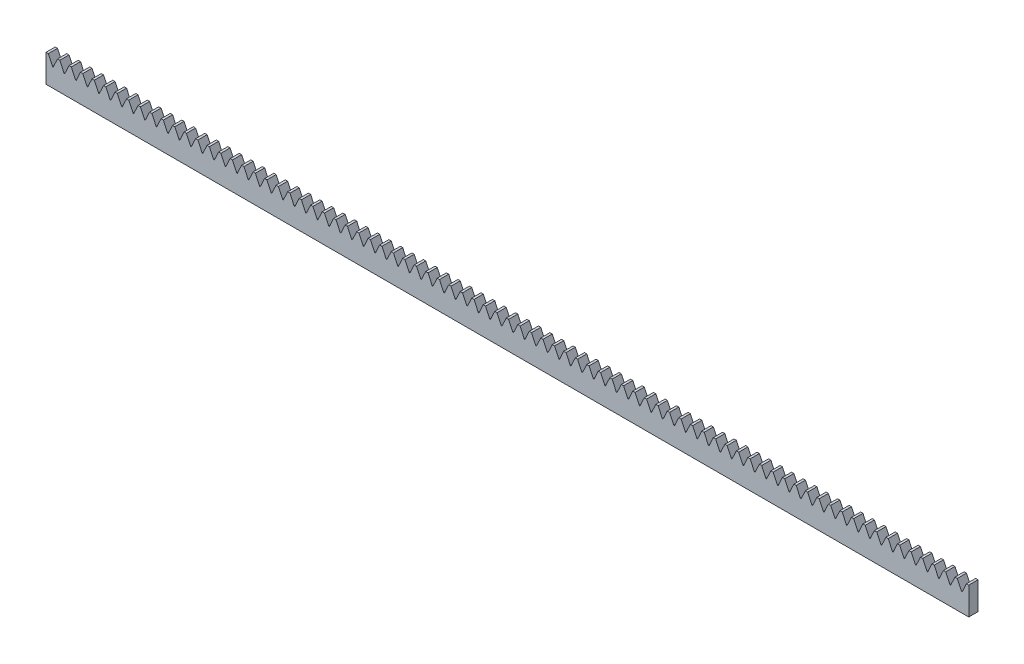
from build123d import *

# Parameters (mm, degrees)
BOSS_EXTRUDE1_DEPTH = 10


with BuildPart() as part:
    # Sketch2 → Boss-Extrude1 (new body)
    with BuildSketch(Plane.XY):
        with BuildLine():
            Line((0, 0), (0, 30))
            Line((0, 30), (2.5, 30))
            Line((2.5, 30), (7.028457818, 20.288690869))
            ThreePointArc((7.028457818, 20.288690869), (7.481611712, 20), (7.934765605, 20.288690869))
            Line((7.934765605, 20.288690869), (12.463223424, 30))
            Line((12.463223424, 30), (14.963223424, 30))
            Line((14.963223424, 30), (19.491681242, 20.288690869))
            ThreePointArc((19.491681242, 20.288690869), (19.944835136, 20), (20.397989029, 20.288690869))
            Line((20.397989029, 20.288690869), (24.926446848, 30))
            Line((24.926446848, 30), (27.426446848, 30))
            Line((27.426446848, 30), (31.954904666, 20.288690869))
            ThreePointArc((31.954904666, 20.288690869), (32.40805856, 20), (32.861212453, 20.288690869))
            Line((32.861212453, 20.288690869), (37.389670272, 30))
            Line((37.389670272, 30), (39.889670272, 30))
            Line((39.889670272, 30), (44.41812809, 20.288690869))
            ThreePointArc((44.41812809, 20.288690869), (44.871281984, 20), (45.324435877, 20.288690869))
            Line((45.324435877, 20.288690869), (49.852893696, 30))
            Line((49.852893696, 30), (52.352893696, 30))
            Line((52.352893696, 30), (56.881351514, 20.288690869))
            ThreePointArc((56.881351514, 20.288690869), (57.334505408, 20), (57.787659301, 20.288690869))
            Line((57.787659301, 20.288690869), (62.31611712, 30))
            Line((62.31611712, 30), (64.81611712, 30))
            Line((64.81611712, 30), (69.344574938, 20.288690869))
            ThreePointArc((69.344574938, 20.288690869), (69.797728831, 20), (70.250882725, 20.288690869))
            Line((70.250882725, 20.288690869), (74.779340543, 30))
            Line((74.779340543, 30), (77.279340543, 30))
            Line((77.279340543, 30), (81.807798362, 20.288690869))
            ThreePointArc((81.807798362, 20.288690869), (82.260952255, 20), (82.714106149, 20.288690869))
            Line((82.714106149, 20.288690869), (87.242563967, 30))
            Line((87.242563967, 30), (89.742563967, 30))
            Line((89.742563967, 30), (94.271021786, 20.288690869))
            ThreePointArc((94.271021786, 20.288690869), (94.724175679, 20), (95.177329573, 20.288690869))
            Line((95.177329573, 20.288690869), (99.705787391, 30))
            Line((99.705787391, 30), (102.205787391, 30))
            Line((102.205787391, 30), (106.73424521, 20.288690869))
            ThreePointArc((106.73424521, 20.288690869), (107.187399103, 20), (107.640552997, 20.288690869))
            Line((107.640552997, 20.288690869), (112.169010815, 30))
            Line((112.169010815, 30), (114.669010815, 30))
            Line((114.669010815, 30), (119.197468634, 20.288690869))
            ThreePointArc((119.197468634, 20.288690869), (119.650622527, 20), (120.103776421, 20.288690869))
            Line((120.103776421, 20.288690869), (124.632234239, 30))
            Line((124.632234239, 30), (127.132234239, 30))
            Line((127.132234239, 30), (131.660692058, 20.288690869))
            ThreePointArc((131.660692058, 20.288690869), (132.113845951, 20), (132.566999845, 20.288690869))
            Line((132.566999845, 20.288690869), (137.095457663, 30))
            Line((137.095457663, 30), (139.595457663, 30))
            Line((139.595457663, 30), (144.123915481, 20.288690869))
            ThreePointArc((144.123915481, 20.288690869), (144.577069375, 20), (145.030223268, 20.288690869))
            Line((145.030223268, 20.288690869), (149.558681087, 30))
            Line((149.558681087, 30), (152.058681087, 30))
            Line((152.058681087, 30), (156.587138905, 20.288690869))
            ThreePointArc((156.587138905, 20.288690869), (157.040292799, 20), (157.493446692, 20.288690869))
            Line((157.493446692, 20.288690869), (162.021904511, 30))
            Line((162.021904511, 30), (164.521904511, 30))
            Line((164.521904511, 30), (169.050362329, 20.288690869))
            ThreePointArc((169.050362329, 20.288690869), (169.503516223, 20), (169.956670116, 20.288690869))
            Line((169.956670116, 20.288690869), (174.485127935, 30))
            Line((174.485127935, 30), (176.985127935, 30))
            Line((176.985127935, 30), (181.513585753, 20.288690869))
            ThreePointArc((181.513585753, 20.288690869), (181.966739647, 20), (182.41989354, 20.288690869))
            Line((182.41989354, 20.288690869), (186.948351359, 30))
            Line((186.948351359, 30), (189.448351359, 30))
            Line((189.448351359, 30), (193.976809177, 20.288690869))
            ThreePointArc((193.976809177, 20.288690869), (194.429963071, 20), (194.883116964, 20.288690869))
            Line((194.883116964, 20.288690869), (199.411574783, 30))
            Line((199.411574783, 30), (201.911574783, 30))
            Line((201.911574783, 30), (206.440032601, 20.288690869))
            ThreePointArc((206.440032601, 20.288690869), (206.893186494, 20), (207.346340388, 20.288690869))
            Line((207.346340388, 20.288690869), (211.874798206, 30))
            Line((211.874798206, 30), (214.374798206, 30))
            Line((214.374798206, 30), (218.903256025, 20.288690869))
            ThreePointArc((218.903256025, 20.288690869), (219.356409918, 20), (219.809563812, 20.288690869))
            Line((219.809563812, 20.288690869), (224.33802163, 30))
            Line((224.33802163, 30), (226.83802163, 30))
            Line((226.83802163, 30), (231.366479449, 20.288690869))
            ThreePointArc((231.366479449, 20.288690869), (231.819633342, 20), (232.272787236, 20.288690869))
            Line((232.272787236, 20.288690869), (236.801245054, 30))
            Line((236.801245054, 30), (239.301245054, 30))
            Line((239.301245054, 30), (243.829702873, 20.288690869))
            ThreePointArc((243.829702873, 20.288690869), (244.282856766, 20), (244.73601066, 20.288690869))
            Line((244.73601066, 20.288690869), (249.264468478, 30))
            Line((249.264468478, 30), (251.764468478, 30))
            Line((251.764468478, 30), (256.292926297, 20.288690869))
            ThreePointArc((256.292926297, 20.288690869), (256.74608019, 20), (257.199234084, 20.288690869))
            Line((257.199234084, 20.288690869), (261.727691902, 30))
            Line((261.727691902, 30), (264.227691902, 30))
            Line((264.227691902, 30), (268.75614972, 20.288690869))
            ThreePointArc((268.75614972, 20.288690869), (269.209303614, 20), (269.662457508, 20.288690869))
            Line((269.662457508, 20.288690869), (274.190915326, 30))
            Line((274.190915326, 30), (276.690915326, 30))
            Line((276.690915326, 30), (281.219373144, 20.288690869))
            ThreePointArc((281.219373144, 20.288690869), (281.672527038, 20), (282.125680931, 20.288690869))
            Line((282.125680931, 20.288690869), (286.65413875, 30))
            Line((286.65413875, 30), (289.15413875, 30))
            Line((289.15413875, 30), (293.682596568, 20.288690869))
            ThreePointArc((293.682596568, 20.288690869), (294.135750462, 20), (294.588904355, 20.288690869))
            Line((294.588904355, 20.288690869), (299.117362174, 30))
            Line((299.117362174, 30), (301.617362174, 30))
            Line((301.617362174, 30), (306.145819992, 20.288690869))
            ThreePointArc((306.145819992, 20.288690869), (306.598973886, 20), (307.052127779, 20.288690869))
            Line((307.052127779, 20.288690869), (311.580585598, 30))
            Line((311.580585598, 30), (314.080585598, 30))
            Line((314.080585598, 30), (318.609043416, 20.288690869))
            ThreePointArc((318.609043416, 20.288690869), (319.06219731, 20), (319.515351203, 20.288690869))
            Line((319.515351203, 20.288690869), (324.043809022, 30))
            Line((324.043809022, 30), (326.543809022, 30))
            Line((326.543809022, 30), (331.07226684, 20.288690869))
            ThreePointArc((331.07226684, 20.288690869), (331.525420734, 20), (331.978574627, 20.288690869))
            Line((331.978574627, 20.288690869), (336.507032446, 30))
            Line((336.507032446, 30), (339.007032446, 30))
            Line((339.007032446, 30), (343.535490264, 20.288690869))
            ThreePointArc((343.535490264, 20.288690869), (343.988644157, 20), (344.441798051, 20.288690869))
            Line((344.441798051, 20.288690869), (348.970255869, 30))
            Line((348.970255869, 30), (351.470255869, 30))
            Line((351.470255869, 30), (355.998713688, 20.288690869))
            ThreePointArc((355.998713688, 20.288690869), (356.451867581, 20), (356.905021475, 20.288690869))
            Line((356.905021475, 20.288690869), (361.433479293, 30))
            Line((361.433479293, 30), (363.933479293, 30))
            Line((363.933479293, 30), (368.461937112, 20.288690869))
            ThreePointArc((368.461937112, 20.288690869), (368.915091005, 20), (369.368244899, 20.288690869))
            Line((369.368244899, 20.288690869), (373.896702717, 30))
            Line((373.896702717, 30), (376.396702717, 30))
            Line((376.396702717, 30), (380.925160536, 20.288690869))
            ThreePointArc((380.925160536, 20.288690869), (381.378314429, 20), (381.831468323, 20.288690869))
            Line((381.831468323, 20.288690869), (386.359926141, 30))
            Line((386.359926141, 30), (388.859926141, 30))
            Line((388.859926141, 30), (393.38838396, 20.288690869))
            ThreePointArc((393.38838396, 20.288690869), (393.841537853, 20), (394.294691747, 20.288690869))
            Line((394.294691747, 20.288690869), (398.823149565, 30))
            Line((398.823149565, 30), (401.323149565, 30))
            Line((401.323149565, 30), (405.851607383, 20.288690869))
            ThreePointArc((405.851607383, 20.288690869), (406.304761277, 20), (406.757915171, 20.288690869))
            Line((406.757915171, 20.288690869), (411.286372989, 30))
            Line((411.286372989, 30), (413.786372989, 30))
            Line((413.786372989, 30), (418.314830807, 20.288690869))
            ThreePointArc((418.314830807, 20.288690869), (418.767984701, 20), (419.221138594, 20.288690869))
            Line((419.221138594, 20.288690869), (423.749596413, 30))
            Line((423.749596413, 30), (426.249596413, 30))
            Line((426.249596413, 30), (430.778054231, 20.288690869))
            ThreePointArc((430.778054231, 20.288690869), (431.231208125, 20), (431.684362018, 20.288690869))
            Line((431.684362018, 20.288690869), (436.212819837, 30))
            Line((436.212819837, 30), (438.712819837, 30))
            Line((438.712819837, 30), (443.241277655, 20.288690869))
            ThreePointArc((443.241277655, 20.288690869), (443.694431549, 20), (444.147585442, 20.288690869))
            Line((444.147585442, 20.288690869), (448.676043261, 30))
            Line((448.676043261, 30), (451.176043261, 30))
            Line((451.176043261, 30), (455.704501079, 20.288690869))
            ThreePointArc((455.704501079, 20.288690869), (456.157654973, 20), (456.610808866, 20.288690869))
            Line((456.610808866, 20.288690869), (461.139266685, 30))
            Line((461.139266685, 30), (463.639266685, 30))
            Line((463.639266685, 30), (468.167724503, 20.288690869))
            ThreePointArc((468.167724503, 20.288690869), (468.620878397, 20), (469.07403229, 20.288690869))
            Line((469.07403229, 20.288690869), (473.602490108, 30))
            Line((473.602490108, 30), (476.102490108, 30))
            Line((476.102490108, 30), (480.630947927, 20.288690869))
            ThreePointArc((480.630947927, 20.288690869), (481.08410182, 20), (481.537255714, 20.288690869))
            Line((481.537255714, 20.288690869), (486.065713532, 30))
            Line((486.065713532, 30), (488.565713532, 30))
            Line((488.565713532, 30), (493.094171351, 20.288690869))
            ThreePointArc((493.094171351, 20.288690869), (493.547325244, 20), (494.000479138, 20.288690869))
            Line((494.000479138, 20.288690869), (498.528936956, 30))
            Line((498.528936956, 30), (501.028936956, 30))
            Line((501.028936956, 30), (505.557394775, 20.288690869))
            ThreePointArc((505.557394775, 20.288690869), (506.010548668, 20), (506.463702562, 20.288690869))
            Line((506.463702562, 20.288690869), (510.99216038, 30))
            Line((510.99216038, 30), (513.49216038, 30))
            Line((513.49216038, 30), (518.020618199, 20.288690869))
            ThreePointArc((518.020618199, 20.288690869), (518.473772092, 20), (518.926925986, 20.288690869))
            Line((518.926925986, 20.288690869), (523.455383804, 30))
            Line((523.455383804, 30), (525.955383804, 30))
            Line((525.955383804, 30), (530.483841623, 20.288690869))
            ThreePointArc((530.483841623, 20.288690869), (530.936995516, 20), (531.39014941, 20.288690869))
            Line((531.39014941, 20.288690869), (535.918607228, 30))
            Line((535.918607228, 30), (538.418607228, 30))
            Line((538.418607228, 30), (542.947065046, 20.288690869))
            ThreePointArc((542.947065046, 20.288690869), (543.40021894, 20), (543.853372833, 20.288690869))
            Line((543.853372833, 20.288690869), (548.381830652, 30))
            Line((548.381830652, 30), (550.881830652, 30))
            Line((550.881830652, 30), (555.41028847, 20.288690869))
            ThreePointArc((555.41028847, 20.288690869), (555.863442364, 20), (556.316596257, 20.288690869))
            Line((556.316596257, 20.288690869), (560.845054076, 30))
            Line((560.845054076, 30), (563.345054076, 30))
            Line((563.345054076, 30), (567.873511894, 20.288690869))
            ThreePointArc((567.873511894, 20.288690869), (568.326665788, 20), (568.779819681, 20.288690869))
            Line((568.779819681, 20.288690869), (573.3082775, 30))
            Line((573.3082775, 30), (575.8082775, 30))
            Line((575.8082775, 30), (580.336735318, 20.288690869))
            ThreePointArc((580.336735318, 20.288690869), (580.789889212, 20), (581.243043105, 20.288690869))
            Line((581.243043105, 20.288690869), (585.771500924, 30))
            Line((585.771500924, 30), (588.271500924, 30))
            Line((588.271500924, 30), (592.799958742, 20.288690869))
            ThreePointArc((592.799958742, 20.288690869), (593.253112636, 20), (593.706266529, 20.288690869))
            Line((593.706266529, 20.288690869), (598.234724348, 30))
            Line((598.234724348, 30), (600.734724348, 30))
            Line((600.734724348, 30), (605.263182166, 20.288690869))
            ThreePointArc((605.263182166, 20.288690869), (605.71633606, 20), (606.169489953, 20.288690869))
            Line((606.169489953, 20.288690869), (610.697947771, 30))
            Line((610.697947771, 30), (613.197947771, 30))
            Line((613.197947771, 30), (617.72640559, 20.288690869))
            ThreePointArc((617.72640559, 20.288690869), (618.179559483, 20), (618.632713377, 20.288690869))
            Line((618.632713377, 20.288690869), (623.161171195, 30))
            Line((623.161171195, 30), (625.661171195, 30))
            Line((625.661171195, 30), (630.189629014, 20.288690869))
            ThreePointArc((630.189629014, 20.288690869), (630.642782907, 20), (631.095936801, 20.288690869))
            Line((631.095936801, 20.288690869), (635.624394619, 30))
            Line((635.624394619, 30), (638.124394619, 30))
            Line((638.124394619, 30), (642.652852438, 20.288690869))
            ThreePointArc((642.652852438, 20.288690869), (643.106006331, 20), (643.559160225, 20.288690869))
            Line((643.559160225, 20.288690869), (648.087618043, 30))
            Line((648.087618043, 30), (650.587618043, 30))
            Line((650.587618043, 30), (655.116075862, 20.288690869))
            ThreePointArc((655.116075862, 20.288690869), (655.569229755, 20), (656.022383649, 20.288690869))
            Line((656.022383649, 20.288690869), (660.550841467, 30))
            Line((660.550841467, 30), (663.050841467, 30))
            Line((663.050841467, 30), (667.579299286, 20.288690869))
            ThreePointArc((667.579299286, 20.288690869), (668.032453179, 20), (668.485607073, 20.288690869))
            Line((668.485607073, 20.288690869), (673.014064891, 30))
            Line((673.014064891, 30), (675.514064891, 30))
            Line((675.514064891, 30), (680.042522709, 20.288690869))
            ThreePointArc((680.042522709, 20.288690869), (680.495676603, 20), (680.948830496, 20.288690869))
            Line((680.948830496, 20.288690869), (685.477288315, 30))
            Line((685.477288315, 30), (687.977288315, 30))
            Line((687.977288315, 30), (692.505746133, 20.288690869))
            ThreePointArc((692.505746133, 20.288690869), (692.958900027, 20), (693.41205392, 20.288690869))
            Line((693.41205392, 20.288690869), (697.940511739, 30))
            Line((697.940511739, 30), (700.440511739, 30))
            Line((700.440511739, 30), (704.968969557, 20.288690869))
            ThreePointArc((704.968969557, 20.288690869), (705.422123451, 20), (705.875277344, 20.288690869))
            Line((705.875277344, 20.288690869), (710.403735163, 30))
            Line((710.403735163, 30), (712.903735163, 30))
            Line((712.903735163, 30), (717.432192981, 20.288690869))
            ThreePointArc((717.432192981, 20.288690869), (717.885346875, 20), (718.338500768, 20.288690869))
            Line((718.338500768, 20.288690869), (722.866958587, 30))
            Line((722.866958587, 30), (725.366958587, 30))
            Line((725.366958587, 30), (729.895416405, 20.288690869))
            ThreePointArc((729.895416405, 20.288690869), (730.348570299, 20), (730.801724192, 20.288690869))
            Line((730.801724192, 20.288690869), (735.330182011, 30))
            Line((735.330182011, 30), (737.830182011, 30))
            Line((737.830182011, 30), (742.358639829, 20.288690869))
            ThreePointArc((742.358639829, 20.288690869), (742.811793722, 20), (743.264947616, 20.288690869))
            Line((743.264947616, 20.288690869), (747.793405434, 30))
            Line((747.793405434, 30), (750.293405434, 30))
            Line((750.293405434, 30), (754.821863253, 20.288690869))
            ThreePointArc((754.821863253, 20.288690869), (755.275017146, 20), (755.72817104, 20.288690869))
            Line((755.72817104, 20.288690869), (760.256628858, 30))
            Line((760.256628858, 30), (762.756628858, 30))
            Line((762.756628858, 30), (767.285086677, 20.288690869))
            ThreePointArc((767.285086677, 20.288690869), (767.73824057, 20), (768.191394464, 20.288690869))
            Line((768.191394464, 20.288690869), (772.719852282, 30))
            Line((772.719852282, 30), (775.219852282, 30))
            Line((775.219852282, 30), (779.748310101, 20.288690869))
            ThreePointArc((779.748310101, 20.288690869), (780.201463994, 20), (780.654617888, 20.288690869))
            Line((780.654617888, 20.288690869), (785.183075706, 30))
            Line((785.183075706, 30), (787.683075706, 30))
            Line((787.683075706, 30), (792.211533525, 20.288690869))
            ThreePointArc((792.211533525, 20.288690869), (792.664687418, 20), (793.117841312, 20.288690869))
            Line((793.117841312, 20.288690869), (797.64629913, 30))
            Line((797.64629913, 30), (800.14629913, 30))
            Line((800.14629913, 30), (804.674756949, 20.288690869))
            ThreePointArc((804.674756949, 20.288690869), (805.127910842, 20), (805.581064736, 20.288690869))
            Line((805.581064736, 20.288690869), (810.109522554, 30))
            Line((810.109522554, 30), (812.609522554, 30))
            Line((812.609522554, 30), (817.137980372, 20.288690869))
            ThreePointArc((817.137980372, 20.288690869), (817.591134266, 20), (818.044288159, 20.288690869))
            Line((818.044288159, 20.288690869), (822.572745978, 30))
            Line((822.572745978, 30), (825.072745978, 30))
            Line((825.072745978, 30), (829.601203796, 20.288690869))
            ThreePointArc((829.601203796, 20.288690869), (830.05435769, 20), (830.507511583, 20.288690869))
            Line((830.507511583, 20.288690869), (835.035969402, 30))
            Line((835.035969402, 30), (837.535969402, 30))
            Line((837.535969402, 30), (842.06442722, 20.288690869))
            ThreePointArc((842.06442722, 20.288690869), (842.517581114, 20), (842.970735007, 20.288690869))
            Line((842.970735007, 20.288690869), (847.499192826, 30))
            Line((847.499192826, 30), (849.999192826, 30))
            Line((849.999192826, 30), (854.527650644, 20.288690869))
            ThreePointArc((854.527650644, 20.288690869), (854.980804538, 20), (855.433958431, 20.288690869))
            Line((855.433958431, 20.288690869), (859.96241625, 30))
            Line((859.96241625, 30), (862.46241625, 30))
            Line((862.46241625, 30), (866.990874068, 20.288690869))
            ThreePointArc((866.990874068, 20.288690869), (867.444027962, 20), (867.897181855, 20.288690869))
            Line((867.897181855, 20.288690869), (872.425639674, 30))
            Line((872.425639674, 30), (874.925639674, 30))
            Line((874.925639674, 30), (879.454097492, 20.288690869))
            ThreePointArc((879.454097492, 20.288690869), (879.907251385, 20), (880.360405279, 20.288690869))
            Line((880.360405279, 20.288690869), (884.888863097, 30))
            Line((884.888863097, 30), (887.388863097, 30))
            Line((887.388863097, 30), (891.917320916, 20.288690869))
            ThreePointArc((891.917320916, 20.288690869), (892.370474809, 20), (892.823628703, 20.288690869))
            Line((892.823628703, 20.288690869), (897.352086521, 30))
            Line((897.352086521, 30), (899.852086521, 30))
            Line((899.852086521, 30), (904.38054434, 20.288690869))
            ThreePointArc((904.38054434, 20.288690869), (904.833698233, 20), (905.286852127, 20.288690869))
            Line((905.286852127, 20.288690869), (909.815309945, 30))
            Line((909.815309945, 30), (912.315309945, 30))
            Line((912.315309945, 30), (916.843767764, 20.288690869))
            ThreePointArc((916.843767764, 20.288690869), (917.296921657, 20), (917.750075551, 20.288690869))
            Line((917.750075551, 20.288690869), (922.278533369, 30))
            Line((922.278533369, 30), (924.778533369, 30))
            Line((924.778533369, 30), (929.306991188, 20.288690869))
            ThreePointArc((929.306991188, 20.288690869), (929.760145081, 20), (930.213298975, 20.288690869))
            Line((930.213298975, 20.288690869), (934.741756793, 30))
            Line((934.741756793, 30), (937.241756793, 30))
            Line((937.241756793, 30), (941.770214611, 20.288690869))
            ThreePointArc((941.770214611, 20.288690869), (942.223368505, 20), (942.676522399, 20.288690869))
            Line((942.676522399, 20.288690869), (947.204980217, 30))
            Line((947.204980217, 30), (949.704980217, 30))
            Line((949.704980217, 30), (954.233438035, 20.288690869))
            ThreePointArc((954.233438035, 20.288690869), (954.686591929, 20), (955.139745822, 20.288690869))
            Line((955.139745822, 20.288690869), (959.668203641, 30))
            Line((959.668203641, 30), (962.168203641, 30))
            Line((962.168203641, 30), (966.696661459, 20.288690869))
            ThreePointArc((966.696661459, 20.288690869), (967.149815353, 20), (967.602969246, 20.288690869))
            Line((967.602969246, 20.288690869), (972.131427065, 30))
            Line((972.131427065, 30), (974.631427065, 30))
            Line((974.631427065, 30), (979.159884883, 20.288690869))
            ThreePointArc((979.159884883, 20.288690869), (979.613038777, 20), (980.06619267, 20.288690869))
            Line((980.06619267, 20.288690869), (984.594650489, 30))
            Line((984.594650489, 30), (987.094650489, 30))
            Line((987.094650489, 30), (991.623108307, 20.288690869))
            ThreePointArc((991.623108307, 20.288690869), (992.076262201, 20), (992.529416094, 20.288690869))
            Line((992.529416094, 20.288690869), (997.057873913, 30))
            Line((997.057873913, 30), (999.557873913, 30))
            Line((999.557873913, 30), (999.557873913, 0))
            Line((999.557873913, 0), (0, 0))
        make_face()
    extrude(amount=-BOSS_EXTRUDE1_DEPTH)


solid = part.part
